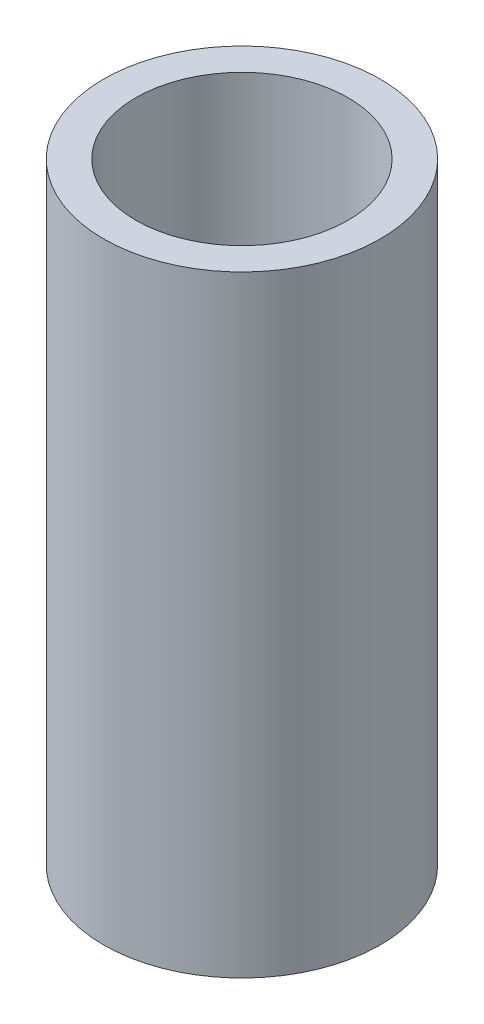
from build123d import *

# Parameters (mm, degrees)
SKETCH1_R           = 2.15
SKETCH1_R_2         = 1.65
BOSS_EXTRUDE1_DEPTH = 9.5


with BuildPart() as part:
    # Sketch1 → Boss-Extrude1 (new body)
    with BuildSketch(Plane(origin=(0, 0, 0), x_dir=(1, 0, 0), z_dir=(0, 1, 0))):
        Circle(SKETCH1_R)
        Circle(SKETCH1_R_2, mode=Mode.SUBTRACT)
    extrude(amount=BOSS_EXTRUDE1_DEPTH)


solid = part.part
